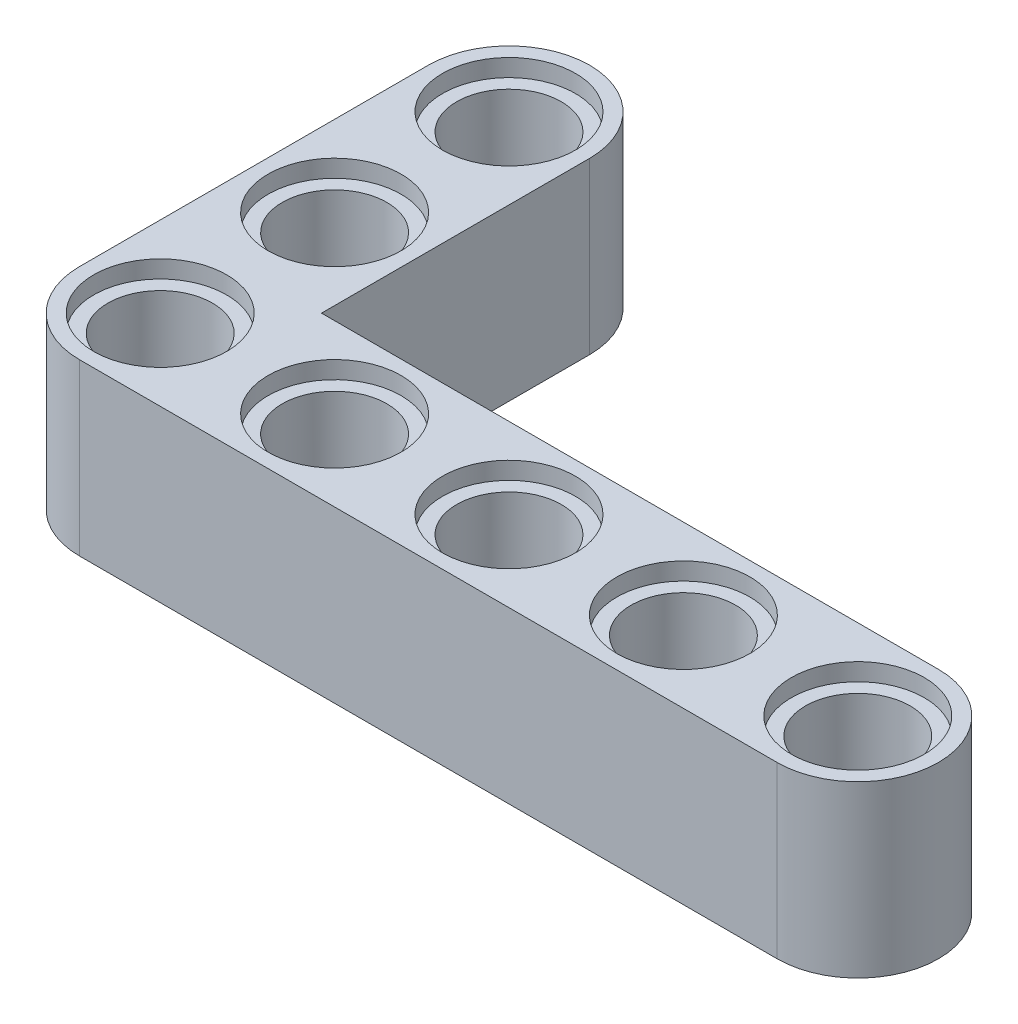
from build123d import *

# Parameters (mm, degrees)
BOSS_EXTRUDE3_DEPTH = 7.8
SKETCH2_R           = 2.4
CUT_EXTRUDE9_DEPTH  = 7.8
SKETCH3_R           = 3.05
CUT_EXTRUDE10_DEPTH = 0.8
SKETCH4_R           = 3.05
CUT_EXTRUDE11_DEPTH = 0.8


with BuildPart() as part:
    # Sketch1 → Boss-Extrude3 (new body)
    with BuildSketch(Plane(origin=(0, 0, 0), x_dir=(1, 0, 0), z_dir=(0, 1, 0))):
        with BuildLine():
            Line((-12.3, 3.7), (16, 3.7))
            ThreePointArc((16, 3.7), (19.7, 0), (16, -3.7))
            Line((16, -3.7), (-16, -3.7))
            ThreePointArc((-16, -3.7), (-18.61629509, -2.61629509), (-19.7, 0))
            Line((-19.7, 0), (-19.7, 16))
            ThreePointArc((-19.7, 16), (-16, 19.7), (-12.3, 16))
            Line((-12.3, 16), (-12.3, 3.7))
        make_face()
    extrude(amount=BOSS_EXTRUDE3_DEPTH)

    # Sketch2 → Cut-Extrude9 (cut)
    with BuildSketch(Plane(origin=(0, 7.8, 0), x_dir=(1, 0, 0), z_dir=(0, 1, 0))):
        Circle(SKETCH2_R)
        with Locations((8, 0)):
            Circle(SKETCH2_R)
        with Locations((16, 0)):
            Circle(SKETCH2_R)
        with Locations((-16, 0)):
            Circle(SKETCH2_R)
        with Locations((-8, 0)):
            Circle(SKETCH2_R)
        with Locations((-16, 16)):
            Circle(SKETCH2_R)
        with Locations((-16, 8)):
            Circle(SKETCH2_R)
    extrude(amount=-CUT_EXTRUDE9_DEPTH, mode=Mode.SUBTRACT)

    # Sketch3 → Cut-Extrude10 (cut)
    with BuildSketch(Plane(origin=(0, 7.8, 0), x_dir=(1, 0, 0), z_dir=(0, 1, 0))):
        Circle(SKETCH3_R)
        with Locations((8, 0)):
            Circle(SKETCH3_R)
        with Locations((16, 0)):
            Circle(SKETCH3_R)
        with Locations((-16, 0)):
            Circle(SKETCH3_R)
        with Locations((-8, 0)):
            Circle(SKETCH3_R)
        with Locations((-16, 8)):
            Circle(SKETCH3_R)
        with Locations((-16, 16)):
            Circle(SKETCH3_R)
    extrude(amount=-CUT_EXTRUDE10_DEPTH, mode=Mode.SUBTRACT)

    # Sketch4 → Cut-Extrude11 (cut)
    with BuildSketch(Plane.XZ):
        Circle(SKETCH4_R)
        with Locations((8, 0)):
            Circle(SKETCH4_R)
        with Locations((16, 0)):
            Circle(SKETCH4_R)
        with Locations((-16, 0)):
            Circle(SKETCH4_R)
        with Locations((-8, 0)):
            Circle(SKETCH4_R)
        with Locations((-16, -8)):
            Circle(SKETCH4_R)
        with Locations((-16, -16)):
            Circle(SKETCH4_R)
    extrude(amount=-CUT_EXTRUDE11_DEPTH, mode=Mode.SUBTRACT)


solid = part.part
